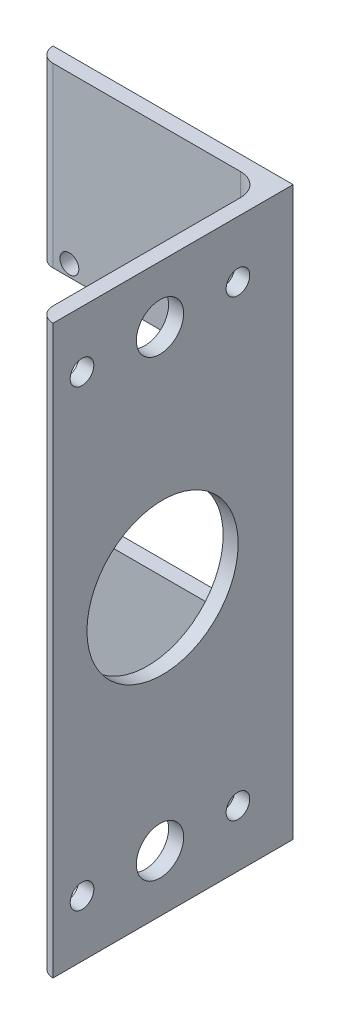
from build123d import *

# Parameters (mm, degrees)
HIERRO_ANGULAR_2_X_2_X_0_125_1_DEPTH = 120
CROQUIS3_W                           = 47.625
CROQUIS3_H                           = 45
CORTAR_EXTRUIR1_DEPTH                = 10
CROQUIS4_R                           = 5
CROQUIS4_R_2                         = 2.5
CORTAR_EXTRUIR2_DEPTH                = 10
CROQUIS5_R                           = 16
CORTAR_EXTRUIR3_DEPTH                = 3.175
CROQUIS6_R                           = 2
CORTAR_EXTRUIR4_DEPTH                = 3.175


with BuildPart() as part:
    # Sketch1 → Hierro angular 2 X 2 X 0.125(1) (new body)
    with BuildSketch(Plane(origin=(0, 0, 0), x_dir=(-1, 0, 0), z_dir=(0, 1, 0))):
        with BuildLine():
            Line((0, 0), (0, 50.8))
            Line((0, 50.8), (0.00508, 50.8))
            ThreePointArc((0.00508, 50.8), (2.246551928, 49.871551928), (3.175, 47.63008))
            Line((3.175, 47.63008), (3.175, 7.9375))
            ThreePointArc((3.175, 7.9375), (4.569903955, 4.569903955), (7.9375, 3.175))
            Line((7.9375, 3.175), (47.63008, 3.175))
            ThreePointArc((47.63008, 3.175), (49.871551928, 2.246551928), (50.8, 0.00508))
            Line((50.8, 0.00508), (50.8, 0))
            Line((50.8, 0), (0, 0))
        make_face()
    extrude(amount=HIERRO_ANGULAR_2_X_2_X_0_125_1_DEPTH)

    # Croquis3 → Cortar-Extruir1 (cut)
    with BuildSketch(Plane(origin=(0, 0, 0), x_dir=(-1, 0, 0), z_dir=(0, 0, -1))):
        with Locations((26.9875, 60)):
            Rectangle(CROQUIS3_W, CROQUIS3_H)
    extrude(amount=-CORTAR_EXTRUIR1_DEPTH, mode=Mode.SUBTRACT)

    # Croquis4 → Cortar-Extruir2 (cut)
    with BuildSketch(Plane.ZY.offset(3.175)):
        with Locations((28.175, 12)):
            Circle(CROQUIS4_R)
        with Locations((11.675, 12)):
            Circle(CROQUIS4_R_2)
        with Locations((44.675, 12)):
            Circle(CROQUIS4_R_2)
        with Locations((44.675, 108)):
            Circle(CROQUIS4_R_2)
        with Locations((28.175, 108)):
            Circle(CROQUIS4_R)
        with Locations((11.675, 108)):
            Circle(CROQUIS4_R_2)
    extrude(amount=-CORTAR_EXTRUIR2_DEPTH, mode=Mode.SUBTRACT)

    # Croquis5 → Cortar-Extruir3 (cut)
    with BuildSketch(Plane.ZY.offset(3.175)):
        with Locations((27.63008, 60)):
            Circle(CROQUIS5_R)
    extrude(amount=-CORTAR_EXTRUIR3_DEPTH, mode=Mode.SUBTRACT)

    # Croquis6 → Cortar-Extruir4 (cut)
    with BuildSketch(Plane(origin=(0, 0, 0), x_dir=(-1, 0, 0), z_dir=(0, 0, -1))):
        with Locations((14.175, 35)):
            Circle(CROQUIS6_R)
        with Locations((14.175, 85)):
            Circle(CROQUIS6_R)
        with Locations((44.175, 85)):
            Circle(CROQUIS6_R)
        with Locations((44.175, 35)):
            Circle(CROQUIS6_R)
    extrude(amount=-CORTAR_EXTRUIR4_DEPTH, mode=Mode.SUBTRACT)


solid = part.part
